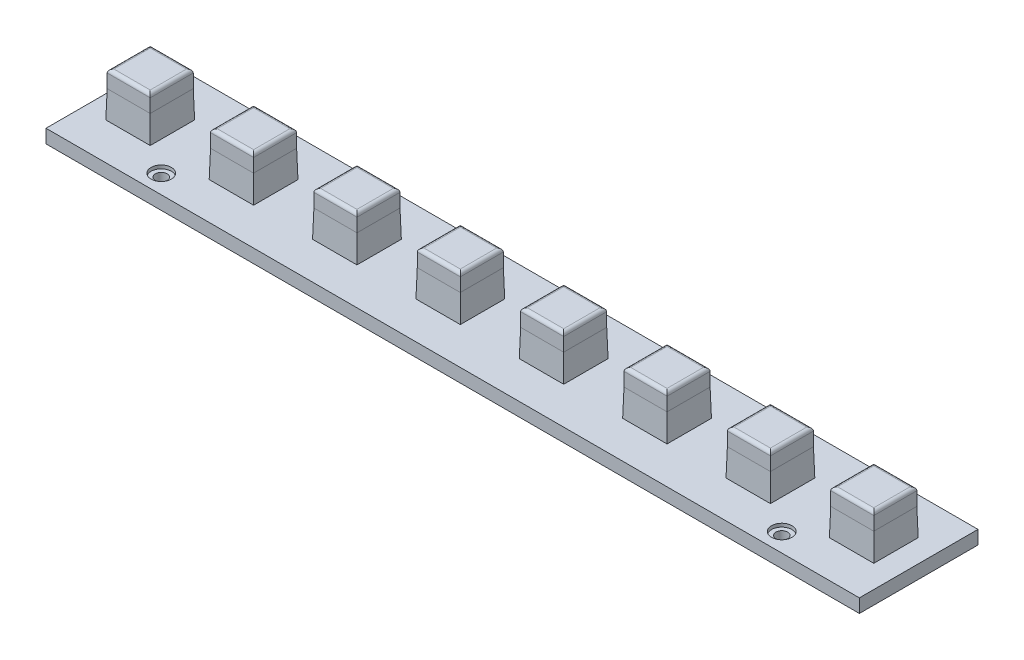
from build123d import *

# Parameters (mm, degrees)
SKETCH1_W                = 240
SKETCH1_H                = 35
SKETCH1_W_2              = 12.7
SKETCH1_H_2              = 12.7
BOSS_EXTRUDE1_DEPTH      = 4
SKETCH2_W                = 12.7
SKETCH2_H                = 12.7
BOSS_EXTRUDE2_DEPTH      = 13
BOSS_EXTRUDE2_DEPTH_BACK = 4
CHAMFER1_SIZE            = 0.2
CHAMFER1_SIZE2           = 8
SKETCH3_R                = 1.725
CUT_EXTRUDE1_DEPTH       = 5
SKETCH4_R                = 3
CUT_EXTRUDE2_DEPTH       = 1
FILLET1_R                = 1


with BuildPart() as part:
    # Sketch1 → Boss-Extrude1 (new body)
    with BuildSketch(Plane(origin=(0, 0, 0), x_dir=(1, 0, 0), z_dir=(0, 1, 0))):
        with Locations((120, 17.5)):
            Rectangle(SKETCH1_W, SKETCH1_H)
        with Locations((13.25, 17.5)):
            Rectangle(SKETCH1_W_2, SKETCH1_H_2, mode=Mode.SUBTRACT)
        with Locations((43.75, 17.5)):
            Rectangle(SKETCH1_W_2, SKETCH1_H_2, mode=Mode.SUBTRACT)
        with Locations((74.25, 17.5)):
            Rectangle(SKETCH1_W_2, SKETCH1_H_2, mode=Mode.SUBTRACT)
        with Locations((104.75, 17.5)):
            Rectangle(SKETCH1_W_2, SKETCH1_H_2, mode=Mode.SUBTRACT)
        with Locations((135.25, 17.5)):
            Rectangle(SKETCH1_W_2, SKETCH1_H_2, mode=Mode.SUBTRACT)
        with Locations((165.75, 17.5)):
            Rectangle(SKETCH1_W_2, SKETCH1_H_2, mode=Mode.SUBTRACT)
        with Locations((196.25, 17.5)):
            Rectangle(SKETCH1_W_2, SKETCH1_H_2, mode=Mode.SUBTRACT)
        with Locations((226.75, 17.5)):
            Rectangle(SKETCH1_W_2, SKETCH1_H_2, mode=Mode.SUBTRACT)
    extrude(amount=BOSS_EXTRUDE1_DEPTH)

    # Sketch2 → Boss-Extrude2 (add, two sides)
    with BuildSketch(Plane(origin=(0, 4, 0), x_dir=(1, 0, 0), z_dir=(0, 1, 0))) as boss_extrude2_sk:
        with Locations((13.25, 17.5)):
            Rectangle(SKETCH2_W, SKETCH2_H)
        with Locations((43.75, 17.5)):
            Rectangle(SKETCH2_W, SKETCH2_H)
        with Locations((74.25, 17.5)):
            Rectangle(SKETCH2_W, SKETCH2_H)
        with Locations((104.75, 17.5)):
            Rectangle(SKETCH2_W, SKETCH2_H)
        with Locations((135.25, 17.5)):
            Rectangle(SKETCH2_W, SKETCH2_H)
        with Locations((165.75, 17.5)):
            Rectangle(SKETCH2_W, SKETCH2_H)
        with Locations((196.25, 17.5)):
            Rectangle(SKETCH2_W, SKETCH2_H)
        with Locations((226.75, 17.5)):
            Rectangle(SKETCH2_W, SKETCH2_H)
    extrude(amount=BOSS_EXTRUDE2_DEPTH)
    extrude(boss_extrude2_sk.sketch, amount=-BOSS_EXTRUDE2_DEPTH_BACK)

    # Chamfer1
    chamfer1_edges = [part.edges().sort_by_distance(p)[0] for p in [
        (189.9, 4, -17.5),
        (196.25, 4, -11.15),
        (202.6, 4, -17.5),
        (196.25, 4, -23.85),
        (6.9, 4, -17.5),
        (13.25, 4, -11.15),
        (19.6, 4, -17.5),
        (13.25, 4, -23.85),
        (67.9, 4, -17.5),
        (74.25, 4, -11.15),
        (80.6, 4, -17.5),
        (74.25, 4, -23.85),
        (37.4, 4, -17.5),
        (43.75, 4, -11.15),
        (50.1, 4, -17.5),
        (43.75, 4, -23.85),
        (98.4, 4, -17.5),
        (104.75, 4, -11.15),
        (111.1, 4, -17.5),
        (104.75, 4, -23.85),
        (128.9, 4, -17.5),
        (135.25, 4, -11.15),
        (141.6, 4, -17.5),
        (135.25, 4, -23.85),
        (159.4, 4, -17.5),
        (165.75, 4, -11.15),
        (172.1, 4, -17.5),
        (165.75, 4, -23.85),
        (220.4, 4, -17.5),
        (226.75, 4, -11.15),
        (233.1, 4, -17.5),
        (226.75, 4, -23.85),
    ]]
    chamfer1_side = [part.faces().sort_by_distance(p)[0] for p in [
        (120, 4, -17.5),
    ]]
    chamfer(chamfer1_edges, length=CHAMFER1_SIZE, length2=CHAMFER1_SIZE2, reference=chamfer1_side[0])

    # Sketch3 → Cut-Extrude1 (cut, through all)
    with BuildSketch(Plane(origin=(0, 4, 0), x_dir=(1, 0, 0), z_dir=(0, 1, 0))):
        with Locations((28.5, 5.5)):
            Circle(SKETCH3_R)
        with Locations((28.5, 29.5)):
            Circle(SKETCH3_R)
        with Locations((211.6, 29.5)):
            Circle(SKETCH3_R)
        with Locations((211.6, 5.5)):
            Circle(SKETCH3_R)
    extrude(amount=-CUT_EXTRUDE1_DEPTH, mode=Mode.SUBTRACT)

    # Sketch4 → Cut-Extrude2 (cut)
    with BuildSketch(Plane(origin=(0, 4, 0), x_dir=(1, 0, 0), z_dir=(0, 1, 0))):
        with Locations((28.5, 29.5)):
            Circle(SKETCH4_R)
        with Locations((28.5, 5.5)):
            Circle(SKETCH4_R)
        with Locations((211.6, 5.5)):
            Circle(SKETCH4_R)
        with Locations((211.6, 29.5)):
            Circle(SKETCH4_R)
    extrude(amount=-CUT_EXTRUDE2_DEPTH, mode=Mode.SUBTRACT)

    # Fillet1
    fillet1_edges = [part.edges().sort_by_distance(p)[0] for p in [
        (6.9, 17, -17.5),
        (13.25, 17, -11.15),
        (19.6, 17, -17.5),
        (13.25, 17, -23.85),
        (37.4, 17, -17.5),
        (43.75, 17, -11.15),
        (50.1, 17, -17.5),
        (43.75, 17, -23.85),
        (67.9, 17, -17.5),
        (74.25, 17, -11.15),
        (80.6, 17, -17.5),
        (74.25, 17, -23.85),
        (98.4, 17, -17.5),
        (104.75, 17, -11.15),
        (111.1, 17, -17.5),
        (104.75, 17, -23.85),
        (128.9, 17, -17.5),
        (135.25, 17, -11.15),
        (141.6, 17, -17.5),
        (135.25, 17, -23.85),
        (159.4, 17, -17.5),
        (165.75, 17, -11.15),
        (172.1, 17, -17.5),
        (165.75, 17, -23.85),
        (189.9, 17, -17.5),
        (196.25, 17, -11.15),
        (202.6, 17, -17.5),
        (196.25, 17, -23.85),
        (220.4, 17, -17.5),
        (226.75, 17, -11.15),
        (233.1, 17, -17.5),
        (226.75, 17, -23.85),
    ]]
    fillet(fillet1_edges, radius=FILLET1_R)


solid = part.part
